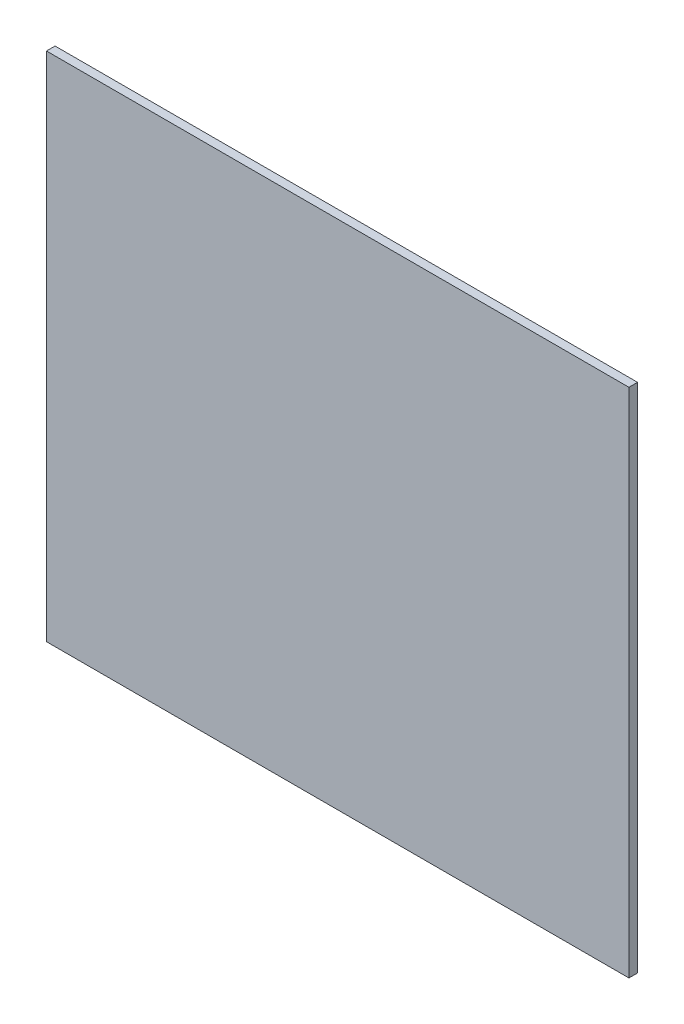
from build123d import *

# Parameters (mm, degrees)
SKETCH1_W           = 115
SKETCH1_H           = 101
BOSS_EXTRUDE1_DEPTH = 1.7


with BuildPart() as part:
    # Sketch1 → Boss-Extrude1 (new body)
    with BuildSketch(Plane.XY):
        with Locations((73.863750802, 57.885409654)):
            Rectangle(SKETCH1_W, SKETCH1_H)
    extrude(amount=BOSS_EXTRUDE1_DEPTH)


solid = part.part
